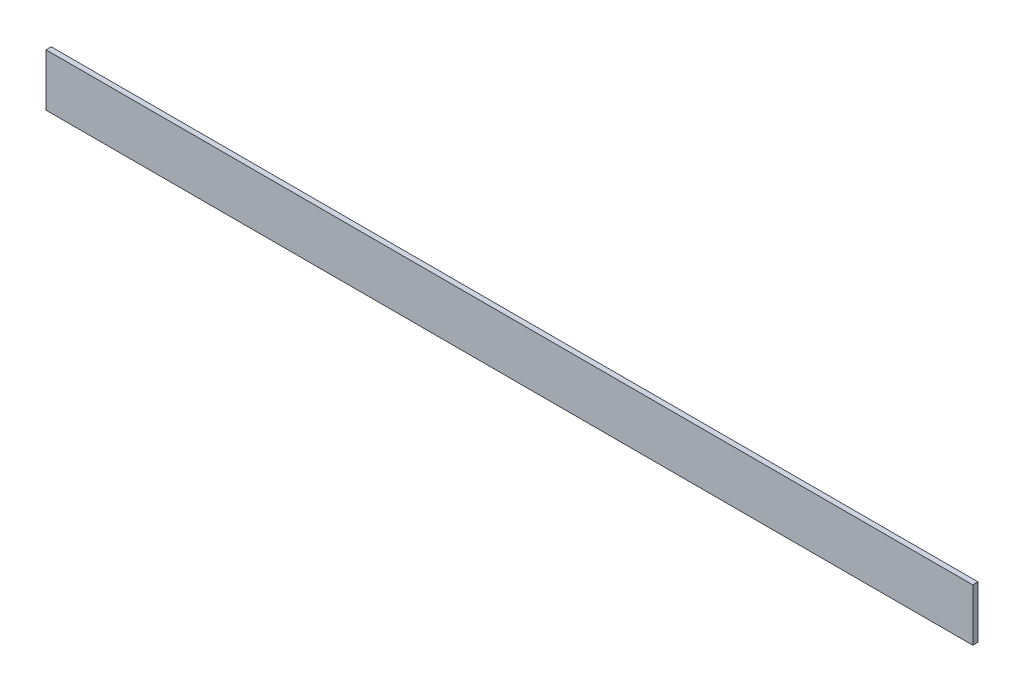
from build123d import *

# Parameters (mm, degrees)
SKETCH1_W           = 354.485
SKETCH1_H           = 20
BOSS_EXTRUDE1_DEPTH = 2


with BuildPart() as part:
    # Sketch1 → Boss-Extrude1 (new body)
    with BuildSketch(Plane.XY):
        with Locations((0.2425, -4.72103784)):
            Rectangle(SKETCH1_W, SKETCH1_H)
    extrude(amount=BOSS_EXTRUDE1_DEPTH)


solid = part.part
